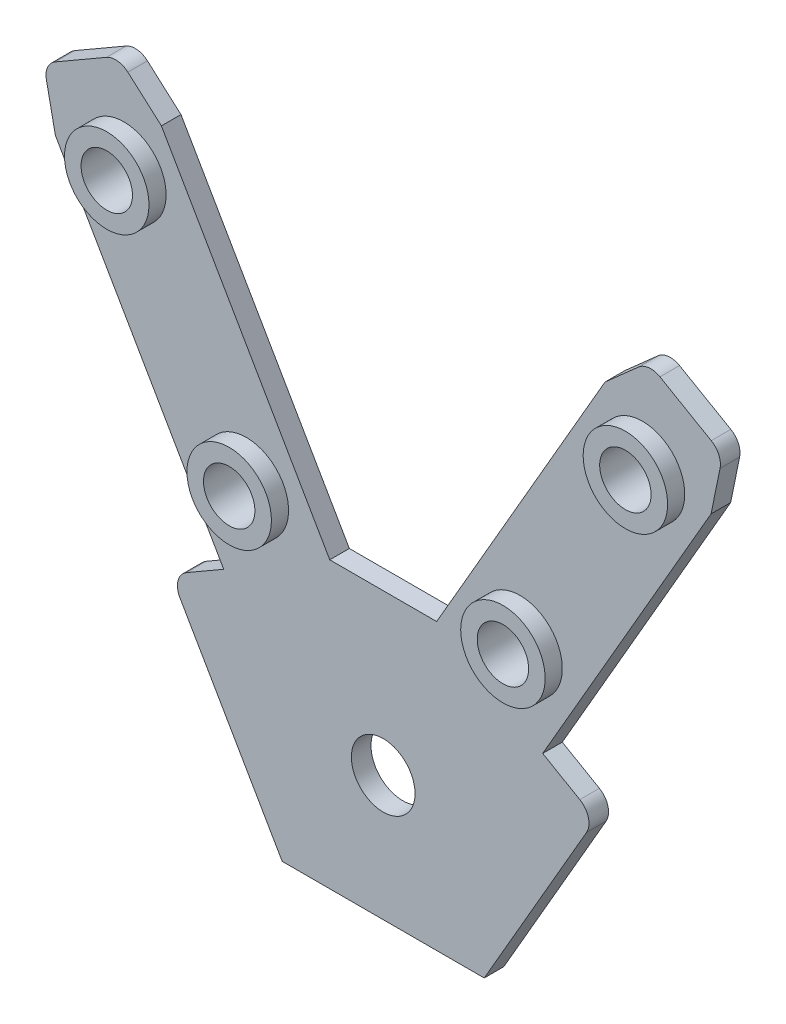
from build123d import *

# Parameters (mm, degrees)
SKETCH1_R             = 2.6
BOSS_EXTRUDE1_DEPTH   = 1.6
SKETCH2_R             = 3.45
BOSS_EXTRUDE2_DEPTH   = 1.4
M5X0_8_TAPPED_HOLE1_D = 4.2


with BuildPart() as part:
    # Sketch1 → Boss-Extrude1 (new body)
    with BuildSketch(Plane.XY):
        with BuildLine():
            Line((-4.364768035, 13.06), (4.364768035, 13.06))
            Line((4.364768035, 13.06), (18.114768035, 36.875698604))
            Line((18.114768035, 36.875698604), (20.854894903, 39.305509792))
            ThreePointArc((20.854894903, 39.305509792), (21.698970531, 39.675572625), (22.600099833, 39.482243506))
            Line((22.600099833, 39.482243506), (26.789690275, 37.063382336))
            ThreePointArc((26.789690275, 37.063382336), (27.407682855, 36.379646028), (27.509236854, 35.463623675))
            Line((27.509236854, 35.463623675), (26.775022073, 31.875698604))
            Line((26.775022073, 31.875698604), (13.025022073, 8.06))
            Line((13.025022073, 8.06), (16.056110986, 6.31))
            ThreePointArc((16.056110986, 6.31), (16.754999726, 5.399190462), (16.605149092, 4.260961894))
            Line((16.605149092, 4.260961894), (8.250335347, -10.21))
            Line((8.250335347, -10.21), (-8.250335347, -10.21))
            Line((-8.250335347, -10.21), (-16.605149092, 4.260961894))
            ThreePointArc((-16.605149092, 4.260961894), (-16.754999726, 5.399190462), (-16.056110986, 6.31))
            Line((-16.056110986, 6.31), (-13.025022073, 8.06))
            Line((-13.025022073, 8.06), (-26.775022073, 31.875698604))
            Line((-26.775022073, 31.875698604), (-27.509236854, 35.463623675))
            ThreePointArc((-27.509236854, 35.463623675), (-27.407682855, 36.379646028), (-26.789690275, 37.063382336))
            Line((-26.789690275, 37.063382336), (-22.600099833, 39.482243506))
            ThreePointArc((-22.600099833, 39.482243506), (-21.698970531, 39.675572625), (-20.854894903, 39.305509792))
            Line((-20.854894903, 39.305509792), (-18.114768035, 36.875698604))
            Line((-18.114768035, 36.875698604), (-4.364768035, 13.06))
        make_face()
        Circle(SKETCH1_R, mode=Mode.SUBTRACT)
    extrude(amount=BOSS_EXTRUDE1_DEPTH)

    # Sketch2 → Boss-Extrude2 (add)
    with BuildSketch(Plane.XY.offset(1.6)):
        with Locations((21.178557159, 32.18233703)):
            Circle(SKETCH2_R)
        with Locations((11.178557159, 14.861828954)):
            Circle(SKETCH2_R)
        with Locations((-11.178557159, 14.861828954)):
            Circle(SKETCH2_R)
        with Locations((-21.178557159, 32.18233703)):
            Circle(SKETCH2_R)
    extrude(amount=BOSS_EXTRUDE2_DEPTH)

    # M5x0.8 Tapped Hole1 (through all)
    with Locations(Plane.XY.offset(3)):
        with Locations((21.178557159, 32.18233703), (11.178557159, 14.861828954), (-11.178557159, 14.861828954), (-21.178557159, 32.18233703)):
            Hole(M5X0_8_TAPPED_HOLE1_D / 2)


solid = part.part
